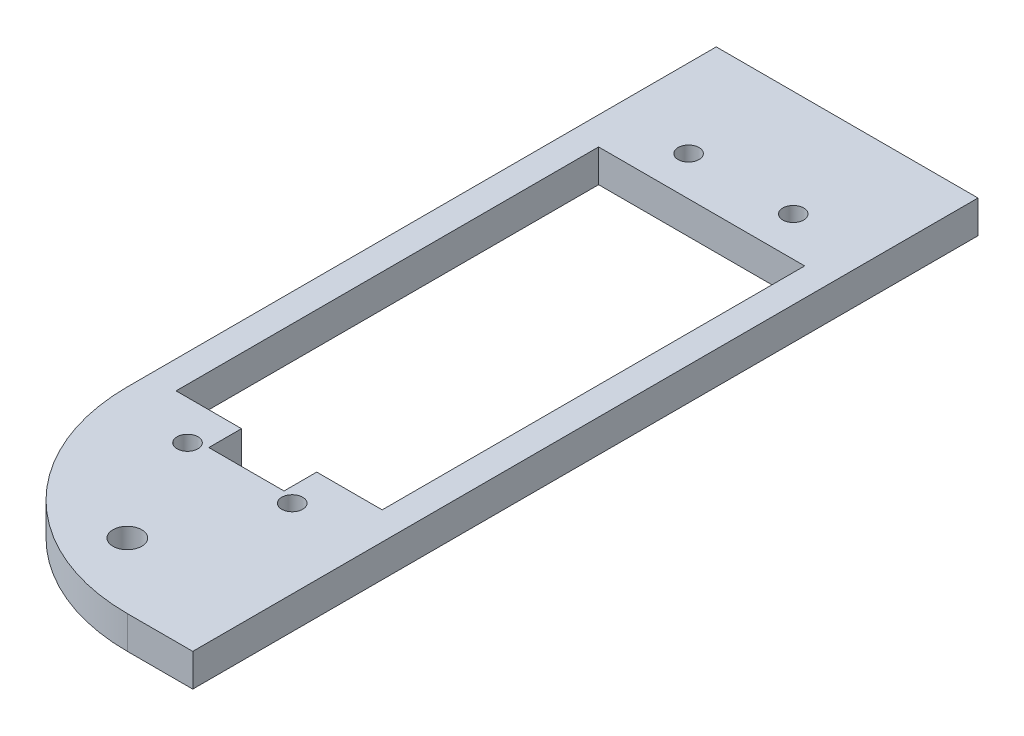
from build123d import *

# Parameters (mm, degrees)
SKETCH1_R           = 1.016
SKETCH1_R_2         = 1.397
BOSS_EXTRUDE1_DEPTH = 3.175


with BuildPart() as part:
    # Sketch1 → Boss-Extrude1 (new body)
    with BuildSketch(Plane.XZ.offset(3.175)):
        with BuildLine():
            Line((12.7, 38.1), (6.35, 38.1))
            ThreePointArc((6.35, 38.1), (-7.120384182, 32.520384182), (-12.7, 19.05))
            Line((-12.7, 19.05), (-12.7, -38.1))
            Line((-12.7, -38.1), (12.7, -38.1))
            Line((12.7, -38.1), (12.7, 38.1))
        make_face()
        with Locations(Location((5.08, 20.828, 0), (0, 0, 90))):  # turned: the seam where the file's is
            Circle(SKETCH1_R, mode=Mode.SUBTRACT)
        with Locations(Location((-5.08, 20.828, 0), (0, 0, 90))):  # turned: the seam where the file's is
            Circle(SKETCH1_R, mode=Mode.SUBTRACT)
        with Locations(Location((-5.08, -27.792, 0), (0, 0, 90))):  # turned: the seam where the file's is
            Circle(SKETCH1_R, mode=Mode.SUBTRACT)
        with Locations(Location((5.08, -27.792, 0), (0, 0, 90))):  # turned: the seam where the file's is
            Circle(SKETCH1_R, mode=Mode.SUBTRACT)
        with Locations(Location((0, 31.75, 0), (0, 0, 90))):  # turned: the seam where the file's is
            Circle(SKETCH1_R_2, mode=Mode.SUBTRACT)
        Polygon((3.65, 17.018), (10, 17.018), (10, -23.982), (-10, -23.982), (-10, 17.018), (-3.65, 17.018), (-3.65, 20.193), (3.65, 20.193), align=None, mode=Mode.SUBTRACT)
    extrude(amount=-BOSS_EXTRUDE1_DEPTH)


solid = part.part
